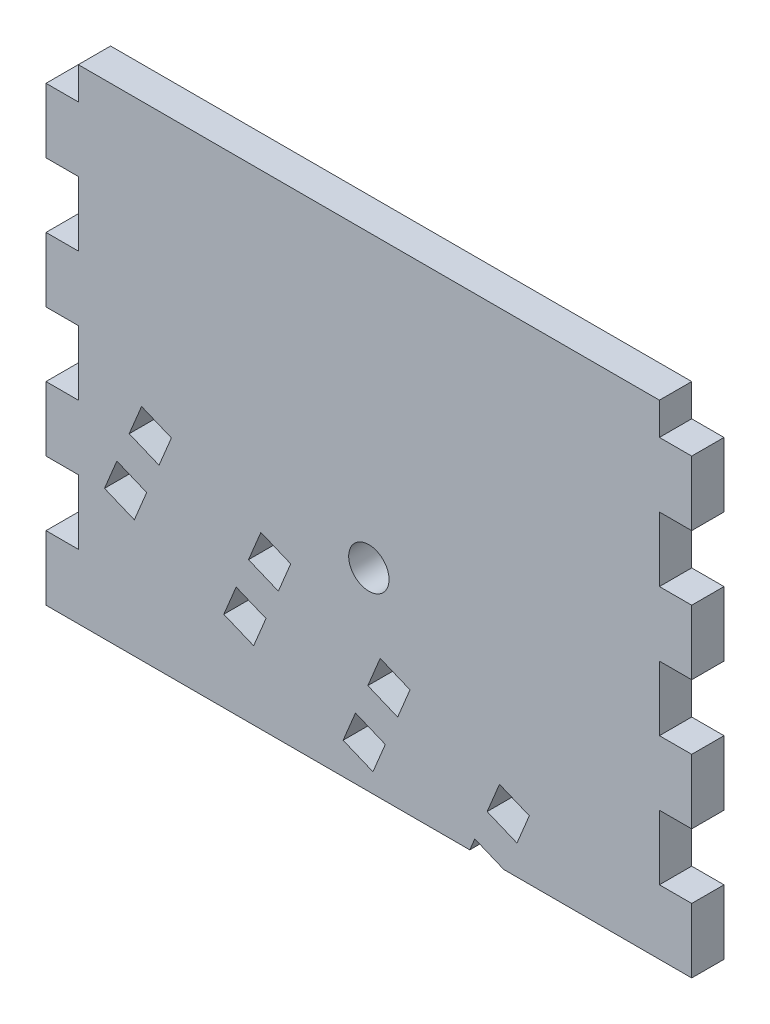
from build123d import *

# Parameters (mm, degrees)
SKETCH1_W           = 127
SKETCH1_H           = 95.25
BOSS_EXTRUDE1_DEPTH = 6.35
SKETCH2_R           = 3.96875
CUT_EXTRUDE1_DEPTH  = 7.35
SKETCH3_W           = 6.35
SKETCH3_H           = 12.7
CUT_EXTRUDE2_DEPTH  = 7.35
SKETCH4_W           = 6.35
SKETCH4_H           = 12.7
CUT_EXTRUDE3_DEPTH  = 7.35
LPATTERN1_COUNT     = 4
LPATTERN1_PITCH     = 25.4
CUT_EXTRUDE4_DEPTH  = 7.35
LPATTERN2_COUNT     = 4
LPATTERN2_PITCH     = 25.4


with BuildPart() as part:
    # Sketch1 → Boss-Extrude1 (new body)
    with BuildSketch(Plane.XY):
        with Locations((63.5, 47.625)):
            Rectangle(SKETCH1_W, SKETCH1_H)
    extrude(amount=BOSS_EXTRUDE1_DEPTH)

    # Sketch2 → Cut-Extrude1 (cut, through all)
    with BuildSketch(Plane.XY.offset(6.35)):
        with Locations((63.5, 38.1)):
            Circle(SKETCH2_R)
    extrude(amount=-CUT_EXTRUDE1_DEPTH, mode=Mode.SUBTRACT)

    # Sketch3 → Cut-Extrude2 (cut, through all)
    with BuildSketch(Plane.XY.offset(6.35)):
        with Locations((3.175, 19.05)):
            Rectangle(SKETCH3_W, SKETCH3_H)
    cut_extrude2 = extrude(amount=-CUT_EXTRUDE2_DEPTH, mode=Mode.SUBTRACT)

    # Sketch4 → Cut-Extrude3 (cut, through all)
    with BuildSketch(Plane.XY.offset(6.35)):
        with Locations((123.825, 19.05)):
            Rectangle(SKETCH4_W, SKETCH4_H)
    cut_extrude3 = extrude(amount=-CUT_EXTRUDE3_DEPTH, mode=Mode.SUBTRACT)

    # LPattern1: Cut-Extrude2, Cut-Extrude3 ×4
    with Locations(*[(0, i * LPATTERN1_PITCH, 0) for i in range(1, LPATTERN1_COUNT)]):
        add(cut_extrude2, mode=Mode.SUBTRACT)
        add(cut_extrude3, mode=Mode.SUBTRACT)

    # Sketch5 → Cut-Extrude4 (cut, through all)
    with BuildSketch(Plane.XY.offset(6.35)):
        Polygon((24.661647272, 40.824853058), (22.231607476, 34.958218027), (16.364972445, 37.388257822), (18.79501224, 43.254892854), align=None)
        Polygon((17.371527885, 23.224947964), (19.801567681, 29.091582995), (13.934932649, 31.521622791), (11.504892854, 25.65498776), align=None)
    cut_extrude4 = extrude(amount=-CUT_EXTRUDE4_DEPTH, mode=Mode.SUBTRACT)

    # LPattern2: Cut-Extrude4 ×4
    with Locations(*[Vector(0.923879533, -0.382683432, 0) * (i * LPATTERN2_PITCH) for i in range(1, LPATTERN2_COUNT)]):
        add(cut_extrude4, mode=Mode.SUBTRACT)


solid = part.part
